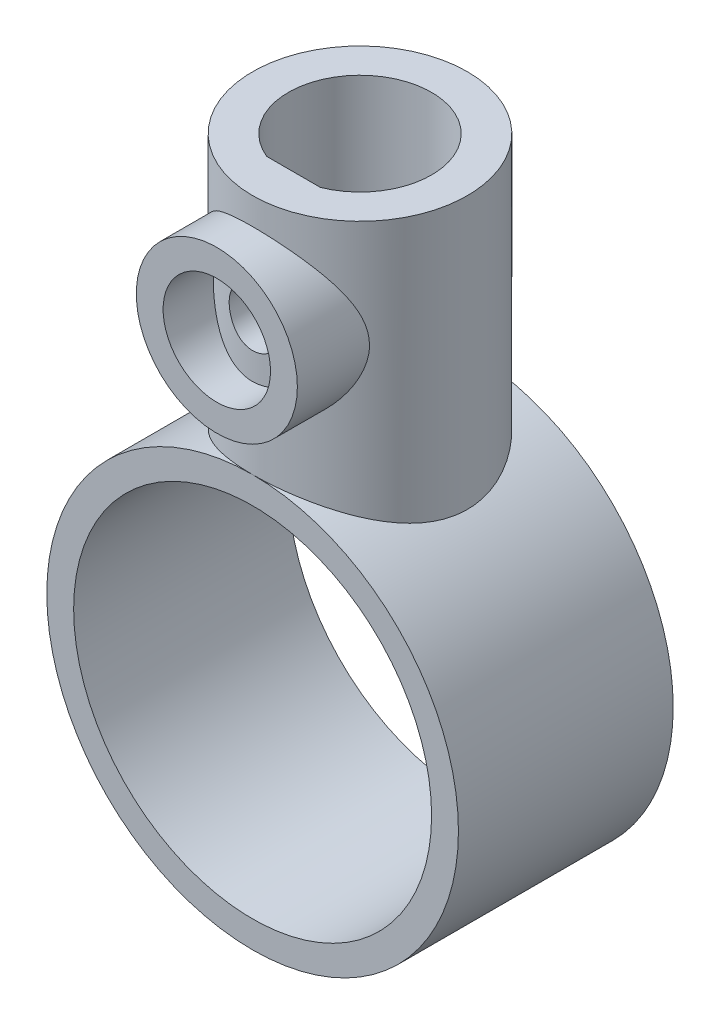
from build123d import *

# Parameters (mm, degrees)
SKETCH1_R               = 11.5
SKETCH1_R_2             = 10
BOSS_EXTRUDE1_DEPTH     = 6
SKETCH2_R               = 6
BOSS_EXTRUDE3_DEPTH     = 18
SKETCH4_R               = 10
CUT_EXTRUDE2_DEPTH      = 7.000000123
CUT_EXTRUDE2_DEPTH_BACK = 7.000000101
SKETCH5_R               = 4
CUT_EXTRUDE3_DEPTH      = 10
SKETCH6_R               = 4.5
SKETCH6_R_2             = 3
BOSS_EXTRUDE4_DEPTH     = 5
SKETCH7_R               = 4
CUT_EXTRUDE4_DEPTH      = 10
BOSS_EXTRUDE5_DEPTH     = 21
SKETCH9_R               = 10
CUT_EXTRUDE5_DEPTH      = 1.0000001
CUT_EXTRUDE5_DEPTH_BACK = 15.0000001
SKETCH10_R              = 1.5
CUT_EXTRUDE6_DEPTH      = 8


with BuildPart() as part:
    # Sketch1 → Boss-Extrude1 (new body, symmetric)
    with BuildSketch(Plane.XY):
        Circle(SKETCH1_R)
        Circle(SKETCH1_R_2, mode=Mode.SUBTRACT)
    extrude(amount=BOSS_EXTRUDE1_DEPTH, both=True)

    # Sketch2 → Boss-Extrude3 (add)
    with BuildSketch(Plane(origin=(0, 25, 0), x_dir=(1, 0, 0), z_dir=(0, 1, 0))):
        Circle(SKETCH2_R)
    extrude(amount=-BOSS_EXTRUDE3_DEPTH)

    # Sketch4 → Cut-Extrude2 (cut, two sides)
    with BuildSketch(Plane.XY) as cut_extrude2_sk:
        Circle(SKETCH4_R)
    extrude(amount=CUT_EXTRUDE2_DEPTH, mode=Mode.SUBTRACT)
    extrude(cut_extrude2_sk.sketch, amount=-CUT_EXTRUDE2_DEPTH_BACK, mode=Mode.SUBTRACT)

    # Sketch5 → Cut-Extrude3 (cut)
    with BuildSketch(Plane(origin=(0, 25, 0), x_dir=(1, 0, 0), z_dir=(0, 1, 0))):
        Circle(SKETCH5_R)
    extrude(amount=-CUT_EXTRUDE3_DEPTH, mode=Mode.SUBTRACT)

    # Sketch6 → Boss-Extrude4 (add)
    with BuildSketch(Plane.XY.offset(8)):
        with Locations((0, 19)):
            Circle(SKETCH6_R)
        with Locations((0, 19)):
            Circle(SKETCH6_R_2, mode=Mode.SUBTRACT)
    extrude(amount=-BOSS_EXTRUDE4_DEPTH)

    # Sketch7 → Cut-Extrude4 (cut)
    with BuildSketch(Plane(origin=(0, 25, 0), x_dir=(1, 0, 0), z_dir=(0, 1, 0))):
        Circle(SKETCH7_R)
    extrude(amount=-CUT_EXTRUDE4_DEPTH, mode=Mode.SUBTRACT)

    # Sketch8 → Boss-Extrude5 (add)
    with BuildSketch(Plane(origin=(0, 25, 0), x_dir=(1, 0, 0), z_dir=(0, 1, 0))):
        with BuildLine():
            Line((-1.5, -3.708099244), (1.5, -3.708099244))
            ThreePointArc((1.5, -3.708099244), (0, -4), (-1.5, -3.708099244))
        make_face()
    extrude(amount=-BOSS_EXTRUDE5_DEPTH)

    # Sketch9 → Cut-Extrude5 (cut, two sides)
    with BuildSketch(Plane.XY.offset(8)) as cut_extrude5_sk:
        Circle(SKETCH9_R)
    extrude(amount=CUT_EXTRUDE5_DEPTH, mode=Mode.SUBTRACT)
    extrude(cut_extrude5_sk.sketch, amount=-CUT_EXTRUDE5_DEPTH_BACK, mode=Mode.SUBTRACT)

    # Sketch10 → Cut-Extrude6 (cut)
    with BuildSketch(Plane.XY.offset(8)):
        with Locations((0, 19)):
            Circle(SKETCH10_R)
    extrude(amount=-CUT_EXTRUDE6_DEPTH, mode=Mode.SUBTRACT)


solid = part.part
